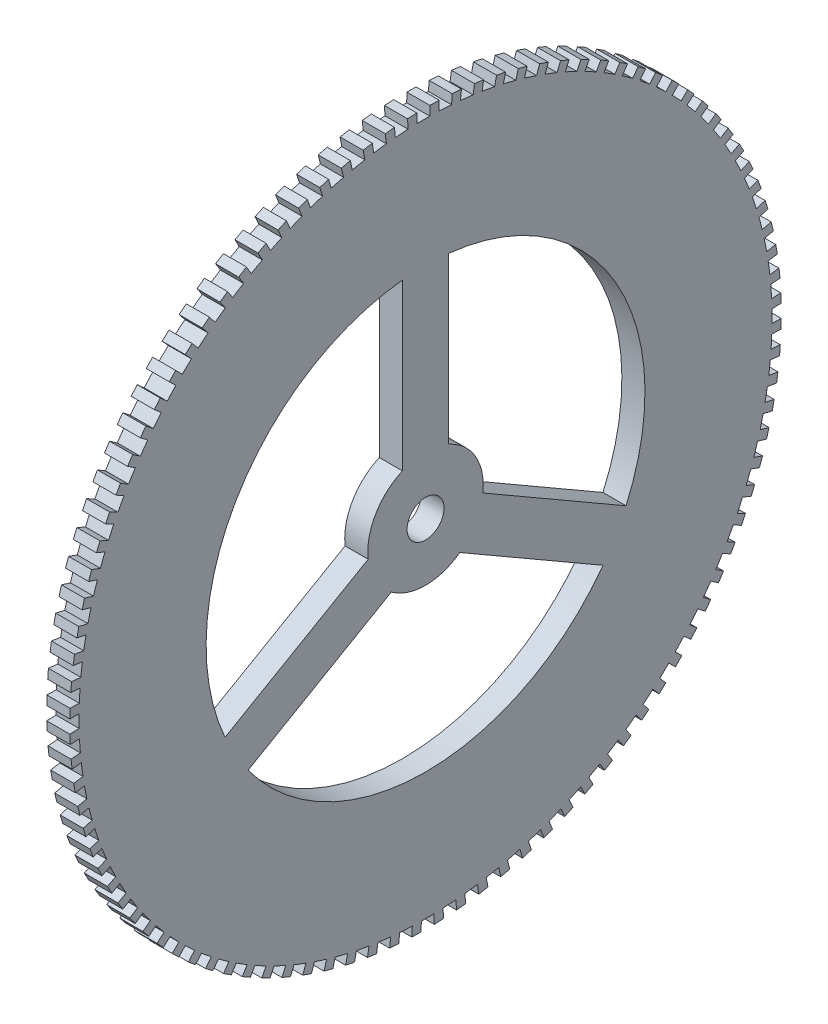
from build123d import *

# Parameters (mm, degrees)
SKETCH1_R           = 4
BOSS_EXTRUDE1_DEPTH = 5


with BuildPart() as part:
    # Sketch1 → Boss-Extrude1 (new body)
    with BuildSketch(Plane(origin=(0, 0, 0), x_dir=(0, 0, -1), z_dir=(1, 0, 0))):
        with BuildLine():
            Line((-26.749399744, 70.067607447), (-27.462717071, 71.936076979))
            Line((-27.462717071, 71.936076979), (-25.594247539, 72.649394305))
            Line((-25.594247539, 72.649394305), (-24.92105681, 70.738539195))
            ThreePointArc((-24.92105681, 70.738539195), (-23.613056573, 71.185838193), (-22.29703444, 71.608953736))
            Line((-22.29703444, 71.608953736), (-22.891622026, 73.518525836))
            Line((-22.891622026, 73.518525836), (-20.982049926, 74.113113421))
            Line((-20.982049926, 74.113113421), (-20.43017117, 72.163758951))
            ThreePointArc((-20.43017117, 72.163758951), (-19.096665836, 72.528045292), (-17.756672928, 72.8676922))
            Line((-17.756672928, 72.8676922), (-18.230184206, 74.810830658))
            Line((-18.230184206, 74.810830658), (-16.287045748, 75.284341937))
            Line((-16.287045748, 75.284341937), (-15.858656979, 73.304181319))
            ThreePointArc((-15.858656979, 73.304181319), (-14.504909284, 73.584017332), (-13.14623394, 73.838855173))
            Line((-13.14623394, 73.838855173), (-13.496800179, 75.80789131))
            Line((-13.496800179, 75.80789131), (-11.527764041, 76.158457549))
            Line((-11.527764041, 76.158457549), (-11.224555913, 74.155305573))
            ThreePointArc((-11.224555913, 74.155305573), (-9.855908482, 74.349586872), (-8.483912773, 74.518609918))
            Line((-8.483912773, 74.518609918), (-8.710150447, 76.505772849))
            Line((-8.710150447, 76.505772849), (-6.722987516, 76.732010523))
            Line((-6.722987516, 76.732010523), (-6.546156653, 74.713772713))
            ThreePointArc((-6.546156653, 74.713772713), (-5.168010911, 74.82173256), (-3.788109478, 74.904273754))
            Line((-3.788109478, 74.904273754), (-3.88912573, 76.901721054))
            Line((-3.88912573, 76.901721054), (-1.89167843, 77.002737307))
            Line((-1.89167843, 77.002737307), (-1.841922704, 74.977378727))
            ThreePointArc((-1.841922704, 74.977378727), (-0.459717563, 74.998591052), (0.922643755, 74.994324642))
            Line((0.922643755, 74.994324642), (0.947247589, 76.994173299))
            Line((0.947247589, 76.994173299), (2.947096246, 76.969569466))
            Line((2.947096246, 76.969569466), (2.869580473, 74.94508328))
            ThreePointArc((2.869580473, 74.94508328), (4.250390081, 74.879464369), (5.629755735, 74.788407192))
            Line((5.629755735, 74.788407192), (5.779882554, 76.782764717))
            Line((5.779882554, 76.782764717), (7.774240079, 76.632637898))
            Line((7.774240079, 76.632637898), (7.569758727, 74.617013829))
            ThreePointArc((7.569758727, 74.617013829), (8.943723377, 74.464822649), (10.31464964, 74.287334067))
            Line((10.31464964, 74.287334067), (10.589706964, 76.268329642))
            Line((10.589706964, 76.268329642), (12.570702539, 75.993272319))
            Line((12.570702539, 75.993272319), (12.240062601, 73.994465114))
            ThreePointArc((12.240062601, 73.994465114), (13.601759883, 73.756302294), (14.958836336, 73.493082773))
            Line((14.958836336, 73.493082773), (15.357738638, 75.452898314))
            Line((15.357738638, 75.452898314), (17.317554178, 75.053996011))
            Line((17.317554178, 75.053996011), (16.862060541, 73.07989405))
            ThreePointArc((16.862060541, 73.07989405), (18.206116456, 72.75669951), (19.543987338, 72.408787857))
            Line((19.543987338, 72.408787857), (20.065160334, 74.339688867))
            Line((20.065160334, 74.339688867), (21.996061343, 73.818515871))
            Line((21.996061343, 73.818515871), (21.41751163, 71.876910031))
            ThreePointArc((21.41751163, 71.876910031), (22.738621806, 71.469959272), (24.052007152, 71.038728536))
            Line((24.052007152, 71.038728536), (24.693394009, 72.93309463))
            Line((24.693394009, 72.93309463), (26.587760103, 72.291707773))
            Line((26.587760103, 72.291707773), (25.888437587, 70.390260685))
            ThreePointArc((25.888437587, 70.390260685), (27.181388203, 69.901159757), (28.465104681, 69.388311807))
            Line((28.465104681, 69.388311807), (29.224174139, 71.238666789))
            Line((29.224174139, 71.238666789), (31.074529121, 70.479597331))
            Line((31.074529121, 70.479597331), (30.257193707, 68.625813139))
            ThreePointArc((30.257193707, 68.625813139), (31.516882079, 68.056492299), (32.765863447, 67.464051113))
            Line((32.765863447, 67.464051113), (33.639619806, 69.263092476))
            Line((33.639619806, 69.263092476), (35.438661169, 68.389336117))
            Line((35.438661169, 68.389336117), (34.506538507, 66.59053086))
            ThreePointArc((34.506538507, 66.59053086), (35.727993221, 65.943236957), (36.937310319, 65.27354063))
            Line((36.937310319, 65.27354063), (37.922305261, 67.01416838))
            Line((37.922305261, 67.01416838), (39.662933011, 66.029173438))
            Line((39.662933011, 66.029173438), (38.619701764, 64.292446179))
            ThreePointArc((38.619701764, 64.292446179), (39.798102295, 63.569733787), (40.962982502, 62.825425303))
            Line((40.962982502, 62.825425303), (42.055328702, 64.500769978))
            Line((42.055328702, 64.500769978), (43.730673377, 63.408423778))
            Line((43.730673377, 63.408423778), (42.580450702, 61.740628585))
            ThreePointArc((42.580450702, 61.740628585), (43.711146442, 60.945349919), (44.826992508, 60.129366725))
            Line((44.826992508, 60.129366725), (46.022378975, 61.732816504))
            Line((46.022378975, 61.732816504), (47.625828754, 60.537430037))
            Line((47.625828754, 60.537430037), (46.373154054, 58.945148936))
            ThreePointArc((46.373154054, 58.945148936), (47.451682664, 58.080442598), (48.514090854, 57.196005006))
            Line((48.514090854, 57.196005006), (49.807799943, 58.721231806))
            Line((49.807799943, 58.721231806), (51.333026743, 57.427522717))
            Line((51.333026743, 57.427522717), (49.982843753, 55.917039714))
            ThreePointArc((49.982843753, 55.917039714), (51.004948773, 54.986318305), (52.009726247, 54.036916786))
            Line((52.009726247, 54.036916786), (53.39665228, 55.477901234))
            Line((53.39665228, 55.477901234), (54.837636727, 54.090975201))
            Line((54.837636727, 54.090975201), (53.395274002, 52.668251483))
            ThreePointArc((53.395274002, 52.668251483), (54.356921651, 51.675188134), (55.300103011, 50.664569543))
            Line((55.300103011, 50.664569543), (56.774772425, 52.015624731))
            Line((56.774772425, 52.015624731), (58.125827612, 50.540955317))
            Line((58.125827612, 50.540955317), (56.596977499, 49.211605724))
            ThreePointArc((56.596977499, 49.211605724), (57.494372592, 48.160119604), (58.372235533, 47.09227239))
            Line((58.372235533, 47.09227239), (59.928828481, 48.34806632))
            Line((59.928828481, 48.34806632), (61.184622411, 46.791473373))
            Line((61.184622411, 46.791473373), (59.575318583, 45.560744241))
            ThreePointArc((59.575318583, 45.560744241), (60.404919512, 44.454985084), (61.213999509, 43.334123552))
            Line((61.213999509, 43.334123552), (62.84637283, 44.489700181))
            Line((62.84637283, 44.489700181), (64.001949458, 42.85732686))
            Line((64.001949458, 42.85732686), (62.318543101, 41.730075314))
            ThreePointArc((62.318543101, 41.730075314), (63.07707581, 40.574407047), (63.814179796, 39.404954727))
            Line((63.814179796, 39.404954727), (65.515891257, 40.455753519))
            Line((65.515891257, 40.455753519), (66.56669005, 38.754042058))
            Line((66.56669005, 38.754042058), (64.815824801, 37.734716846))
            ThreePointArc((64.815824801, 37.734716846), (65.500295708, 36.533700363), (66.162514668, 35.320272547))
            Line((66.162514668, 35.320272547), (67.926848393, 36.262146482))
            Line((67.926848393, 36.262146482), (68.868722327, 34.497812757))
            Line((68.868722327, 34.497812757), (67.057308051, 33.590436689))
            ThreePointArc((67.057308051, 33.590436689), (67.665015862, 32.348811853), (68.249736322, 31.096197388))
            Line((68.249736322, 31.096197388), (70.06972929, 31.925429318))
            Line((70.06972929, 31.925429318), (70.898961221, 30.10543635))
            Line((70.898961221, 30.10543635), (69.034146742, 29.313590424))
            ThreePointArc((69.034146742, 29.313590424), (69.562693113, 28.036257363), (70.067607447, 26.749399744))
            Line((70.067607447, 26.749399744), (71.936076979, 27.462717071))
            Line((71.936076979, 27.462717071), (72.649394305, 25.594247539))
            Line((72.649394305, 25.594247539), (70.738539195, 24.92105681))
            ThreePointArc((70.738539195, 24.92105681), (71.185838193, 23.613056573), (71.608953736, 22.29703444))
            Line((71.608953736, 22.29703444), (73.518525836, 22.891622026))
            Line((73.518525836, 22.891622026), (74.113113421, 20.982049926))
            Line((74.113113421, 20.982049926), (72.163758951, 20.43017117))
            ThreePointArc((72.163758951, 20.43017117), (72.528045292, 19.096665836), (72.8676922, 17.756672928))
            Line((72.8676922, 17.756672928), (74.810830658, 18.230184206))
            Line((74.810830658, 18.230184206), (75.284341937, 16.287045748))
            Line((75.284341937, 16.287045748), (73.304181319, 15.858656979))
            ThreePointArc((73.304181319, 15.858656979), (73.584017332, 14.504909284), (73.838855173, 13.14623394))
            Line((73.838855173, 13.14623394), (75.80789131, 13.496800179))
            Line((75.80789131, 13.496800179), (76.158457549, 11.527764041))
            Line((76.158457549, 11.527764041), (74.155305573, 11.224555913))
            ThreePointArc((74.155305573, 11.224555913), (74.349586872, 9.855908482), (74.518609918, 8.483912773))
            Line((74.518609918, 8.483912773), (76.505772849, 8.710150447))
            Line((76.505772849, 8.710150447), (76.732010523, 6.722987516))
            Line((76.732010523, 6.722987516), (74.713772713, 6.546156653))
            ThreePointArc((74.713772713, 6.546156653), (74.82173256, 5.168010911), (74.904273754, 3.788109478))
            Line((74.904273754, 3.788109478), (76.901721054, 3.88912573))
            Line((76.901721054, 3.88912573), (77.002737307, 1.89167843))
            Line((77.002737307, 1.89167843), (74.977378727, 1.841922704))
            ThreePointArc((74.977378727, 1.841922704), (74.998591052, 0.459717563), (74.994324642, -0.922643755))
            Line((74.994324642, -0.922643755), (76.994173299, -0.947247589))
            Line((76.994173299, -0.947247589), (76.969569466, -2.947096246))
            Line((76.969569466, -2.947096246), (74.94508328, -2.869580473))
            ThreePointArc((74.94508328, -2.869580473), (74.879464369, -4.250390081), (74.788407192, -5.629755735))
            Line((74.788407192, -5.629755735), (76.782764717, -5.779882554))
            Line((76.782764717, -5.779882554), (76.632637898, -7.774240079))
            Line((76.632637898, -7.774240079), (74.617013829, -7.569758727))
            ThreePointArc((74.617013829, -7.569758727), (74.464822649, -8.943723377), (74.287334067, -10.31464964))
            Line((74.287334067, -10.31464964), (76.268329642, -10.589706964))
            Line((76.268329642, -10.589706964), (75.993272319, -12.570702539))
            Line((75.993272319, -12.570702539), (73.994465114, -12.240062601))
            ThreePointArc((73.994465114, -12.240062601), (73.756302294, -13.601759883), (73.493082773, -14.958836336))
            Line((73.493082773, -14.958836336), (75.452898314, -15.357738638))
            Line((75.452898314, -15.357738638), (75.053996011, -17.317554178))
            Line((75.053996011, -17.317554178), (73.07989405, -16.862060541))
            ThreePointArc((73.07989405, -16.862060541), (72.75669951, -18.206116456), (72.408787857, -19.543987338))
            Line((72.408787857, -19.543987338), (74.339688867, -20.065160334))
            Line((74.339688867, -20.065160334), (73.818515871, -21.996061343))
            Line((73.818515871, -21.996061343), (71.876910031, -21.41751163))
            ThreePointArc((71.876910031, -21.41751163), (71.469959272, -22.738621806), (71.038728536, -24.052007152))
            Line((71.038728536, -24.052007152), (72.93309463, -24.693394009))
            Line((72.93309463, -24.693394009), (72.291707773, -26.587760103))
            Line((72.291707773, -26.587760103), (70.390260685, -25.888437587))
            ThreePointArc((70.390260685, -25.888437587), (69.901159757, -27.181388203), (69.388311807, -28.465104681))
            Line((69.388311807, -28.465104681), (71.238666789, -29.224174139))
            Line((71.238666789, -29.224174139), (70.479597331, -31.074529121))
            Line((70.479597331, -31.074529121), (68.625813139, -30.257193707))
            ThreePointArc((68.625813139, -30.257193707), (68.056492299, -31.516882079), (67.464051113, -32.765863447))
            Line((67.464051113, -32.765863447), (69.263092476, -33.639619806))
            Line((69.263092476, -33.639619806), (68.389336117, -35.438661169))
            Line((68.389336117, -35.438661169), (66.59053086, -34.506538507))
            ThreePointArc((66.59053086, -34.506538507), (65.943236957, -35.727993221), (65.27354063, -36.937310319))
            Line((65.27354063, -36.937310319), (67.01416838, -37.922305261))
            Line((67.01416838, -37.922305261), (66.029173438, -39.662933011))
            Line((66.029173438, -39.662933011), (64.292446179, -38.619701764))
            ThreePointArc((64.292446179, -38.619701764), (63.569733787, -39.798102295), (62.825425303, -40.962982502))
            Line((62.825425303, -40.962982502), (64.500769978, -42.055328702))
            Line((64.500769978, -42.055328702), (63.408423778, -43.730673377))
            Line((63.408423778, -43.730673377), (61.740628585, -42.580450702))
            ThreePointArc((61.740628585, -42.580450702), (60.945349919, -43.711146442), (60.129366725, -44.826992508))
            Line((60.129366725, -44.826992508), (61.732816504, -46.022378975))
            Line((61.732816504, -46.022378975), (60.537430037, -47.625828754))
            Line((60.537430037, -47.625828754), (58.945148936, -46.373154054))
            ThreePointArc((58.945148936, -46.373154054), (58.080442598, -47.451682664), (57.196005006, -48.514090854))
            Line((57.196005006, -48.514090854), (58.721231806, -49.807799943))
            Line((58.721231806, -49.807799943), (57.427522717, -51.333026743))
            Line((57.427522717, -51.333026743), (55.917039714, -49.982843753))
            ThreePointArc((55.917039714, -49.982843753), (54.986318305, -51.004948773), (54.036916786, -52.009726247))
            Line((54.036916786, -52.009726247), (55.477901234, -53.39665228))
            Line((55.477901234, -53.39665228), (54.090975201, -54.837636727))
            Line((54.090975201, -54.837636727), (52.668251483, -53.395274002))
            ThreePointArc((52.668251483, -53.395274002), (51.675188134, -54.356921651), (50.664569543, -55.300103011))
            Line((50.664569543, -55.300103011), (52.015624731, -56.774772425))
            Line((52.015624731, -56.774772425), (50.540955317, -58.125827612))
            Line((50.540955317, -58.125827612), (49.211605724, -56.596977499))
            ThreePointArc((49.211605724, -56.596977499), (48.160119604, -57.494372592), (47.09227239, -58.372235533))
            Line((47.09227239, -58.372235533), (48.34806632, -59.928828481))
            Line((48.34806632, -59.928828481), (46.791473373, -61.184622411))
            Line((46.791473373, -61.184622411), (45.560744241, -59.575318583))
            ThreePointArc((45.560744241, -59.575318583), (44.454985084, -60.404919512), (43.334123552, -61.213999509))
            Line((43.334123552, -61.213999509), (44.489700181, -62.84637283))
            Line((44.489700181, -62.84637283), (42.85732686, -64.001949458))
            Line((42.85732686, -64.001949458), (41.730075314, -62.318543101))
            ThreePointArc((41.730075314, -62.318543101), (40.574407047, -63.07707581), (39.404954727, -63.814179796))
            Line((39.404954727, -63.814179796), (40.455753519, -65.515891257))
            Line((40.455753519, -65.515891257), (38.754042058, -66.56669005))
            Line((38.754042058, -66.56669005), (37.734716846, -64.815824801))
            ThreePointArc((37.734716846, -64.815824801), (36.533700363, -65.500295708), (35.320272547, -66.162514668))
            Line((35.320272547, -66.162514668), (36.262146482, -67.926848393))
            Line((36.262146482, -67.926848393), (34.497812757, -68.868722327))
            Line((34.497812757, -68.868722327), (33.590436689, -67.057308051))
            ThreePointArc((33.590436689, -67.057308051), (32.348811853, -67.665015862), (31.096197388, -68.249736322))
            Line((31.096197388, -68.249736322), (31.925429318, -70.06972929))
            Line((31.925429318, -70.06972929), (30.10543635, -70.898961221))
            Line((30.10543635, -70.898961221), (29.313590424, -69.034146742))
            ThreePointArc((29.313590424, -69.034146742), (28.036257363, -69.562693113), (26.749399744, -70.067607447))
            Line((26.749399744, -70.067607447), (27.462717071, -71.936076979))
            Line((27.462717071, -71.936076979), (25.594247539, -72.649394305))
            Line((25.594247539, -72.649394305), (24.92105681, -70.738539195))
            ThreePointArc((24.92105681, -70.738539195), (23.613056573, -71.185838193), (22.29703444, -71.608953736))
            Line((22.29703444, -71.608953736), (22.891622026, -73.518525836))
            Line((22.891622026, -73.518525836), (20.982049926, -74.113113421))
            Line((20.982049926, -74.113113421), (20.43017117, -72.163758951))
            ThreePointArc((20.43017117, -72.163758951), (19.096665836, -72.528045292), (17.756672928, -72.8676922))
            Line((17.756672928, -72.8676922), (18.230184206, -74.810830658))
            Line((18.230184206, -74.810830658), (16.287045748, -75.284341937))
            Line((16.287045748, -75.284341937), (15.858656979, -73.304181319))
            ThreePointArc((15.858656979, -73.304181319), (14.504909284, -73.584017332), (13.14623394, -73.838855173))
            Line((13.14623394, -73.838855173), (13.496800179, -75.80789131))
            Line((13.496800179, -75.80789131), (11.527764041, -76.158457549))
            Line((11.527764041, -76.158457549), (11.224555913, -74.155305573))
            ThreePointArc((11.224555913, -74.155305573), (9.855908482, -74.349586872), (8.483912773, -74.518609918))
            Line((8.483912773, -74.518609918), (8.710150447, -76.505772849))
            Line((8.710150447, -76.505772849), (6.722987516, -76.732010523))
            Line((6.722987516, -76.732010523), (6.546156653, -74.713772713))
            ThreePointArc((6.546156653, -74.713772713), (5.168010911, -74.82173256), (3.788109478, -74.904273754))
            Line((3.788109478, -74.904273754), (3.88912573, -76.901721054))
            Line((3.88912573, -76.901721054), (1.89167843, -77.002737307))
            Line((1.89167843, -77.002737307), (1.841922704, -74.977378727))
            ThreePointArc((1.841922704, -74.977378727), (0.459717563, -74.998591052), (-0.922643755, -74.994324642))
            Line((-0.922643755, -74.994324642), (-0.947247589, -76.994173299))
            Line((-0.947247589, -76.994173299), (-2.947096246, -76.969569466))
            Line((-2.947096246, -76.969569466), (-2.869580473, -74.94508328))
            ThreePointArc((-2.869580473, -74.94508328), (-4.250390081, -74.879464369), (-5.629755734, -74.788407192))
            Line((-5.629755734, -74.788407192), (-5.779882554, -76.782764717))
            Line((-5.779882554, -76.782764717), (-7.774240079, -76.632637898))
            Line((-7.774240079, -76.632637898), (-7.569758727, -74.617013829))
            ThreePointArc((-7.569758727, -74.617013829), (-8.943723377, -74.464822649), (-10.31464964, -74.287334067))
            Line((-10.31464964, -74.287334067), (-10.589706964, -76.268329642))
            Line((-10.589706964, -76.268329642), (-12.570702539, -75.993272319))
            Line((-12.570702539, -75.993272319), (-12.240062601, -73.994465114))
            ThreePointArc((-12.240062601, -73.994465114), (-13.601759883, -73.756302294), (-14.958836336, -73.493082773))
            Line((-14.958836336, -73.493082773), (-15.357738638, -75.452898314))
            Line((-15.357738638, -75.452898314), (-17.317554178, -75.053996011))
            Line((-17.317554178, -75.053996011), (-16.862060541, -73.07989405))
            ThreePointArc((-16.862060541, -73.07989405), (-18.206116456, -72.75669951), (-19.543987338, -72.408787857))
            Line((-19.543987338, -72.408787857), (-20.065160334, -74.339688867))
            Line((-20.065160334, -74.339688867), (-21.996061343, -73.818515871))
            Line((-21.996061343, -73.818515871), (-21.41751163, -71.876910031))
            ThreePointArc((-21.41751163, -71.876910031), (-22.738621806, -71.469959272), (-24.052007152, -71.038728536))
            Line((-24.052007152, -71.038728536), (-24.693394009, -72.93309463))
            Line((-24.693394009, -72.93309463), (-26.587760103, -72.291707773))
            Line((-26.587760103, -72.291707773), (-25.888437587, -70.390260685))
            ThreePointArc((-25.888437587, -70.390260685), (-27.181388203, -69.901159757), (-28.465104681, -69.388311807))
            Line((-28.465104681, -69.388311807), (-29.224174139, -71.238666789))
            Line((-29.224174139, -71.238666789), (-31.074529121, -70.479597331))
            Line((-31.074529121, -70.479597331), (-30.257193707, -68.625813139))
            ThreePointArc((-30.257193707, -68.625813139), (-31.516882079, -68.056492299), (-32.765863447, -67.464051113))
            Line((-32.765863447, -67.464051113), (-33.639619806, -69.263092476))
            Line((-33.639619806, -69.263092476), (-35.438661169, -68.389336117))
            Line((-35.438661169, -68.389336117), (-34.506538507, -66.59053086))
            ThreePointArc((-34.506538507, -66.59053086), (-35.727993221, -65.943236957), (-36.937310319, -65.27354063))
            Line((-36.937310319, -65.27354063), (-37.922305261, -67.01416838))
            Line((-37.922305261, -67.01416838), (-39.662933011, -66.029173438))
            Line((-39.662933011, -66.029173438), (-38.619701764, -64.292446179))
            ThreePointArc((-38.619701764, -64.292446179), (-39.798102295, -63.569733787), (-40.962982502, -62.825425303))
            Line((-40.962982502, -62.825425303), (-42.055328702, -64.500769978))
            Line((-42.055328702, -64.500769978), (-43.730673377, -63.408423778))
            Line((-43.730673377, -63.408423778), (-42.580450702, -61.740628585))
            ThreePointArc((-42.580450702, -61.740628585), (-43.711146442, -60.945349919), (-44.826992508, -60.129366725))
            Line((-44.826992508, -60.129366725), (-46.022378975, -61.732816504))
            Line((-46.022378975, -61.732816504), (-47.625828754, -60.537430037))
            Line((-47.625828754, -60.537430037), (-46.373154054, -58.945148936))
            ThreePointArc((-46.373154054, -58.945148936), (-47.451682664, -58.080442598), (-48.514090854, -57.196005006))
            Line((-48.514090854, -57.196005006), (-49.807799943, -58.721231806))
            Line((-49.807799943, -58.721231806), (-51.333026743, -57.427522717))
            Line((-51.333026743, -57.427522717), (-49.982843753, -55.917039714))
            ThreePointArc((-49.982843753, -55.917039714), (-51.004948773, -54.986318305), (-52.009726247, -54.036916786))
            Line((-52.009726247, -54.036916786), (-53.39665228, -55.477901234))
            Line((-53.39665228, -55.477901234), (-54.837636727, -54.090975201))
            Line((-54.837636727, -54.090975201), (-53.395274002, -52.668251483))
            ThreePointArc((-53.395274002, -52.668251483), (-54.356921651, -51.675188134), (-55.300103011, -50.664569543))
            Line((-55.300103011, -50.664569543), (-56.774772425, -52.015624731))
            Line((-56.774772425, -52.015624731), (-58.125827612, -50.540955317))
            Line((-58.125827612, -50.540955317), (-56.596977499, -49.211605724))
            ThreePointArc((-56.596977499, -49.211605724), (-57.494372592, -48.160119604), (-58.372235533, -47.09227239))
            Line((-58.372235533, -47.09227239), (-59.928828481, -48.34806632))
            Line((-59.928828481, -48.34806632), (-61.184622411, -46.791473373))
            Line((-61.184622411, -46.791473373), (-59.575318583, -45.560744241))
            ThreePointArc((-59.575318583, -45.560744241), (-60.404919512, -44.454985084), (-61.213999509, -43.334123552))
            Line((-61.213999509, -43.334123552), (-62.84637283, -44.489700181))
            Line((-62.84637283, -44.489700181), (-64.001949458, -42.85732686))
            Line((-64.001949458, -42.85732686), (-62.318543101, -41.730075314))
            ThreePointArc((-62.318543101, -41.730075314), (-63.07707581, -40.574407047), (-63.814179796, -39.404954727))
            Line((-63.814179796, -39.404954727), (-65.515891257, -40.455753519))
            Line((-65.515891257, -40.455753519), (-66.56669005, -38.754042058))
            Line((-66.56669005, -38.754042058), (-64.815824801, -37.734716846))
            ThreePointArc((-64.815824801, -37.734716846), (-65.500295708, -36.533700363), (-66.162514668, -35.320272547))
            Line((-66.162514668, -35.320272547), (-67.926848393, -36.262146482))
            Line((-67.926848393, -36.262146482), (-68.868722327, -34.497812757))
            Line((-68.868722327, -34.497812757), (-67.057308051, -33.590436689))
            ThreePointArc((-67.057308051, -33.590436689), (-67.665015862, -32.348811853), (-68.249736322, -31.096197388))
            Line((-68.249736322, -31.096197388), (-70.06972929, -31.925429318))
            Line((-70.06972929, -31.925429318), (-70.898961221, -30.10543635))
            Line((-70.898961221, -30.10543635), (-69.034146742, -29.313590424))
            ThreePointArc((-69.034146742, -29.313590424), (-69.562693113, -28.036257363), (-70.067607447, -26.749399744))
            Line((-70.067607447, -26.749399744), (-71.936076979, -27.462717071))
            Line((-71.936076979, -27.462717071), (-72.649394305, -25.594247539))
            Line((-72.649394305, -25.594247539), (-70.738539195, -24.92105681))
            ThreePointArc((-70.738539195, -24.92105681), (-71.185838193, -23.613056573), (-71.608953736, -22.29703444))
            Line((-71.608953736, -22.29703444), (-73.518525836, -22.891622026))
            Line((-73.518525836, -22.891622026), (-74.113113421, -20.982049926))
            Line((-74.113113421, -20.982049926), (-72.163758951, -20.43017117))
            ThreePointArc((-72.163758951, -20.43017117), (-72.528045292, -19.096665836), (-72.8676922, -17.756672928))
            Line((-72.8676922, -17.756672928), (-74.810830658, -18.230184206))
            Line((-74.810830658, -18.230184206), (-75.284341937, -16.287045748))
            Line((-75.284341937, -16.287045748), (-73.304181319, -15.858656979))
            ThreePointArc((-73.304181319, -15.858656979), (-73.584017332, -14.504909284), (-73.838855173, -13.14623394))
            Line((-73.838855173, -13.14623394), (-75.80789131, -13.496800179))
            Line((-75.80789131, -13.496800179), (-76.158457549, -11.527764041))
            Line((-76.158457549, -11.527764041), (-74.155305573, -11.224555913))
            ThreePointArc((-74.155305573, -11.224555913), (-74.349586872, -9.855908482), (-74.518609918, -8.483912773))
            Line((-74.518609918, -8.483912773), (-76.505772849, -8.710150447))
            Line((-76.505772849, -8.710150447), (-76.732010523, -6.722987516))
            Line((-76.732010523, -6.722987516), (-74.713772713, -6.546156653))
            ThreePointArc((-74.713772713, -6.546156653), (-74.82173256, -5.168010911), (-74.904273754, -3.788109478))
            Line((-74.904273754, -3.788109478), (-76.901721054, -3.88912573))
            Line((-76.901721054, -3.88912573), (-77.002737307, -1.89167843))
            Line((-77.002737307, -1.89167843), (-74.977378727, -1.841922704))
            ThreePointArc((-74.977378727, -1.841922704), (-74.998591052, -0.459717563), (-74.994324642, 0.922643755))
            Line((-74.994324642, 0.922643755), (-76.994173299, 0.947247589))
            Line((-76.994173299, 0.947247589), (-76.969569466, 2.947096246))
            Line((-76.969569466, 2.947096246), (-74.94508328, 2.869580473))
            ThreePointArc((-74.94508328, 2.869580473), (-74.879464369, 4.250390081), (-74.788407192, 5.629755734))
            Line((-74.788407192, 5.629755734), (-76.782764717, 5.779882554))
            Line((-76.782764717, 5.779882554), (-76.632637898, 7.774240079))
            Line((-76.632637898, 7.774240079), (-74.617013829, 7.569758727))
            ThreePointArc((-74.617013829, 7.569758727), (-74.464822649, 8.943723377), (-74.287334067, 10.31464964))
            Line((-74.287334067, 10.31464964), (-76.268329642, 10.589706964))
            Line((-76.268329642, 10.589706964), (-75.993272319, 12.570702539))
            Line((-75.993272319, 12.570702539), (-73.994465114, 12.240062601))
            ThreePointArc((-73.994465114, 12.240062601), (-73.756302294, 13.601759883), (-73.493082773, 14.958836336))
            Line((-73.493082773, 14.958836336), (-75.452898314, 15.357738638))
            Line((-75.452898314, 15.357738638), (-75.053996011, 17.317554178))
            Line((-75.053996011, 17.317554178), (-73.07989405, 16.862060541))
            ThreePointArc((-73.07989405, 16.862060541), (-72.75669951, 18.206116456), (-72.408787857, 19.543987338))
            Line((-72.408787857, 19.543987338), (-74.339688867, 20.065160334))
            Line((-74.339688867, 20.065160334), (-73.818515871, 21.996061343))
            Line((-73.818515871, 21.996061343), (-71.876910031, 21.41751163))
            ThreePointArc((-71.876910031, 21.41751163), (-71.469959272, 22.738621806), (-71.038728536, 24.052007152))
            Line((-71.038728536, 24.052007152), (-72.93309463, 24.693394009))
            Line((-72.93309463, 24.693394009), (-72.291707773, 26.587760103))
            Line((-72.291707773, 26.587760103), (-70.390260685, 25.888437587))
            ThreePointArc((-70.390260685, 25.888437587), (-69.901159757, 27.181388203), (-69.388311807, 28.465104681))
            Line((-69.388311807, 28.465104681), (-71.238666789, 29.224174139))
            Line((-71.238666789, 29.224174139), (-70.479597331, 31.074529121))
            Line((-70.479597331, 31.074529121), (-68.625813139, 30.257193707))
            ThreePointArc((-68.625813139, 30.257193707), (-68.056492299, 31.516882079), (-67.464051113, 32.765863447))
            Line((-67.464051113, 32.765863447), (-69.263092476, 33.639619806))
            Line((-69.263092476, 33.639619806), (-68.389336117, 35.438661169))
            Line((-68.389336117, 35.438661169), (-66.59053086, 34.506538507))
            ThreePointArc((-66.59053086, 34.506538507), (-65.943236957, 35.727993221), (-65.27354063, 36.937310319))
            Line((-65.27354063, 36.937310319), (-67.01416838, 37.922305261))
            Line((-67.01416838, 37.922305261), (-66.029173438, 39.662933011))
            Line((-66.029173438, 39.662933011), (-64.292446179, 38.619701764))
            ThreePointArc((-64.292446179, 38.619701764), (-63.569733787, 39.798102295), (-62.825425303, 40.962982502))
            Line((-62.825425303, 40.962982502), (-64.500769978, 42.055328702))
            Line((-64.500769978, 42.055328702), (-63.408423778, 43.730673377))
            Line((-63.408423778, 43.730673377), (-61.740628585, 42.580450702))
            ThreePointArc((-61.740628585, 42.580450702), (-60.945349919, 43.711146442), (-60.129366725, 44.826992508))
            Line((-60.129366725, 44.826992508), (-61.732816504, 46.022378975))
            Line((-61.732816504, 46.022378975), (-60.537430037, 47.625828754))
            Line((-60.537430037, 47.625828754), (-58.945148936, 46.373154054))
            ThreePointArc((-58.945148936, 46.373154054), (-58.080442598, 47.451682664), (-57.196005006, 48.514090854))
            Line((-57.196005006, 48.514090854), (-58.721231806, 49.807799943))
            Line((-58.721231806, 49.807799943), (-57.427522717, 51.333026743))
            Line((-57.427522717, 51.333026743), (-55.917039714, 49.982843753))
            ThreePointArc((-55.917039714, 49.982843753), (-54.986318305, 51.004948773), (-54.036916786, 52.009726247))
            Line((-54.036916786, 52.009726247), (-55.477901234, 53.39665228))
            Line((-55.477901234, 53.39665228), (-54.090975201, 54.837636727))
            Line((-54.090975201, 54.837636727), (-52.668251483, 53.395274002))
            ThreePointArc((-52.668251483, 53.395274002), (-51.675188134, 54.356921651), (-50.664569543, 55.300103011))
            Line((-50.664569543, 55.300103011), (-52.015624731, 56.774772425))
            Line((-52.015624731, 56.774772425), (-50.540955317, 58.125827612))
            Line((-50.540955317, 58.125827612), (-49.211605724, 56.596977499))
            ThreePointArc((-49.211605724, 56.596977499), (-48.160119604, 57.494372592), (-47.09227239, 58.372235533))
            Line((-47.09227239, 58.372235533), (-48.34806632, 59.928828481))
            Line((-48.34806632, 59.928828481), (-46.791473373, 61.184622411))
            Line((-46.791473373, 61.184622411), (-45.560744241, 59.575318583))
            ThreePointArc((-45.560744241, 59.575318583), (-44.454985084, 60.404919512), (-43.334123552, 61.213999509))
            Line((-43.334123552, 61.213999509), (-44.489700181, 62.84637283))
            Line((-44.489700181, 62.84637283), (-42.85732686, 64.001949458))
            Line((-42.85732686, 64.001949458), (-41.730075314, 62.318543101))
            ThreePointArc((-41.730075314, 62.318543101), (-40.574407047, 63.07707581), (-39.404954727, 63.814179796))
            Line((-39.404954727, 63.814179796), (-40.455753519, 65.515891257))
            Line((-40.455753519, 65.515891257), (-38.754042058, 66.56669005))
            Line((-38.754042058, 66.56669005), (-37.734716846, 64.815824801))
            ThreePointArc((-37.734716846, 64.815824801), (-36.533700363, 65.500295708), (-35.320272547, 66.162514668))
            Line((-35.320272547, 66.162514668), (-36.262146482, 67.926848393))
            Line((-36.262146482, 67.926848393), (-34.497812757, 68.868722327))
            Line((-34.497812757, 68.868722327), (-33.590436689, 67.057308051))
            ThreePointArc((-33.590436689, 67.057308051), (-32.348811853, 67.665015862), (-31.096197388, 68.249736322))
            Line((-31.096197388, 68.249736322), (-31.925429318, 70.06972929))
            Line((-31.925429318, 70.06972929), (-30.10543635, 70.898961221))
            Line((-30.10543635, 70.898961221), (-29.313590424, 69.034146742))
            ThreePointArc((-29.313590424, 69.034146742), (-28.036257363, 69.562693113), (-26.749399744, 70.067607447))
        make_face()
        Circle(SKETCH1_R, mode=Mode.SUBTRACT)
        with BuildLine():
            Line((5, 47.236109069), (5, 11.456439237))
            ThreePointArc((5, 11.456439237), (10.825317547, 6.25), (12.421567416, -1.3980926))
            Line((12.421567416, -1.3980926), (43.40767043, -19.287927516))
            ThreePointArc((43.40767043, -19.287927516), (41.13620668, 23.75), (5, 47.236109069))
        make_face(mode=Mode.SUBTRACT)
        with BuildLine():
            Line((-5, 47.236109069), (-5, 11.456439237))
            ThreePointArc((-5, 11.456439237), (-10.825317547, 6.25), (-12.421567416, -1.3980926))
            Line((-12.421567416, -1.3980926), (-43.40767043, -19.287927516))
            ThreePointArc((-43.40767043, -19.287927516), (-41.13620668, 23.75), (-5, 47.236109069))
        make_face(mode=Mode.SUBTRACT)
        with BuildLine():
            Line((38.40767043, -27.948181554), (7.421567416, -10.058346638))
            ThreePointArc((7.421567416, -10.058346638), (0, -12.5), (-7.421567416, -10.058346638))
            Line((-7.421567416, -10.058346638), (-38.40767043, -27.948181554))
            ThreePointArc((-38.40767043, -27.948181554), (0, -47.5), (38.40767043, -27.948181554))
        make_face(mode=Mode.SUBTRACT)
    extrude(amount=BOSS_EXTRUDE1_DEPTH)


solid = part.part
